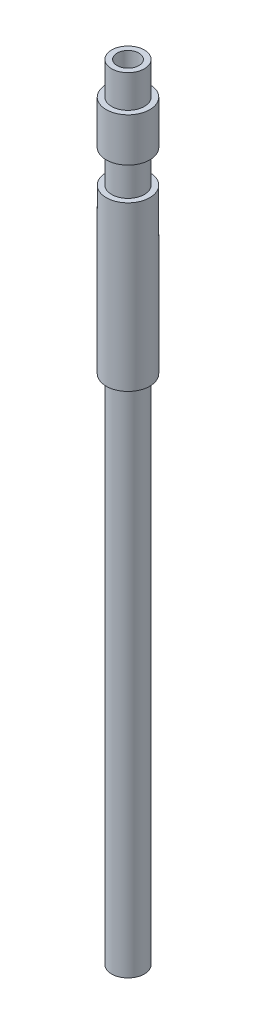
from build123d import *

# Parameters (mm, degrees)
SKETCH_1_R      = 2
SKETCH_1_R_2    = 1
EXTRUDE_1_DEPTH = 72
SKETCH_2_W      = 0.5
SKETCH_2_H      = 3
SKETCH_3_W      = 0.5
SKETCH_3_H      = 47


with BuildPart() as part:
    # Эскиз1 → Бобышка-Вытянуть1 (new body)
    with BuildSketch(Plane(origin=(0, 0, 0), x_dir=(1, 0, 0), z_dir=(0, 1, 0))):
        Circle(SKETCH_1_R)
        Circle(SKETCH_1_R_2, mode=Mode.SUBTRACT)
    extrude(amount=EXTRUDE_1_DEPTH)

    # Эскиз2 → Вырез-Повернуть1 (revolve, cut)
    with BuildSketch(Plane.XY):
        with Locations((1.75, 70.5)):
            Rectangle(SKETCH_2_W, SKETCH_2_H)
        with Locations((1.75, 63.5)):
            Rectangle(SKETCH_2_W, SKETCH_2_H)
    revolve(axis=Axis((0, 72, 0), (0, -1, 0)), mode=Mode.SUBTRACT)

    # Эскиз3 → Вырез-Повернуть2 (revolve, cut)
    with BuildSketch(Plane.XY):
        with Locations((1.75, 23.5)):
            Rectangle(SKETCH_3_W, SKETCH_3_H)
    revolve(axis=Axis((0, 0, 0), (0, 1, 0)), mode=Mode.SUBTRACT)


solid = part.part
